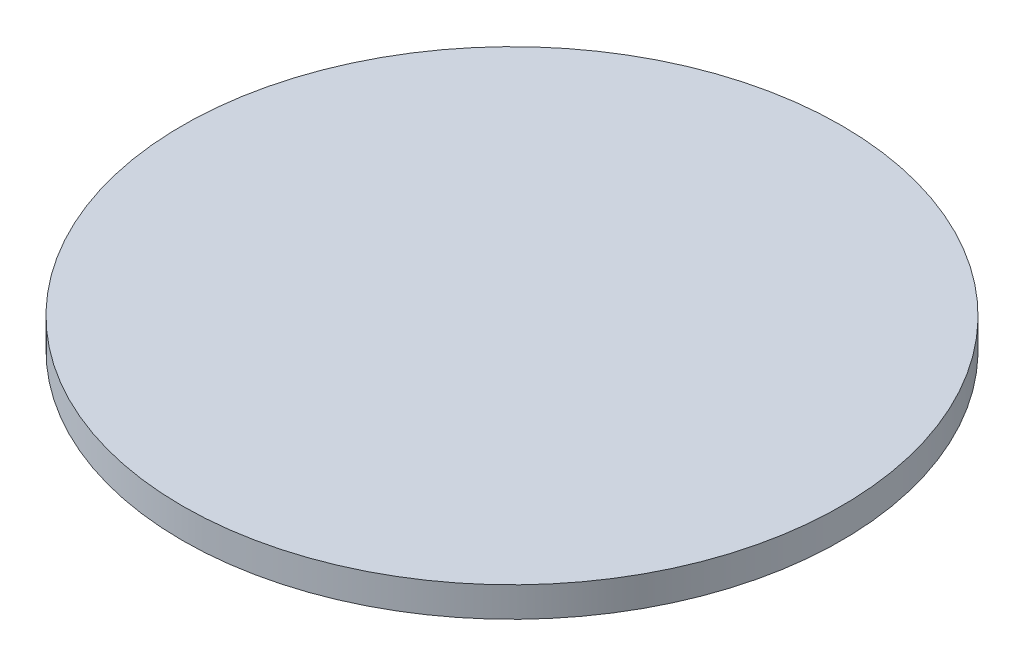
from build123d import *

# Parameters (mm, degrees)
SKETCH1_R           = 35
BOSS_EXTRUDE1_DEPTH = 3.175


with BuildPart() as part:
    # Sketch1 → Boss-Extrude1 (new body)
    with BuildSketch(Plane(origin=(0, 0, 0), x_dir=(1, 0, 0), z_dir=(0, 1, 0))):
        Circle(SKETCH1_R)
    extrude(amount=BOSS_EXTRUDE1_DEPTH)


solid = part.part
